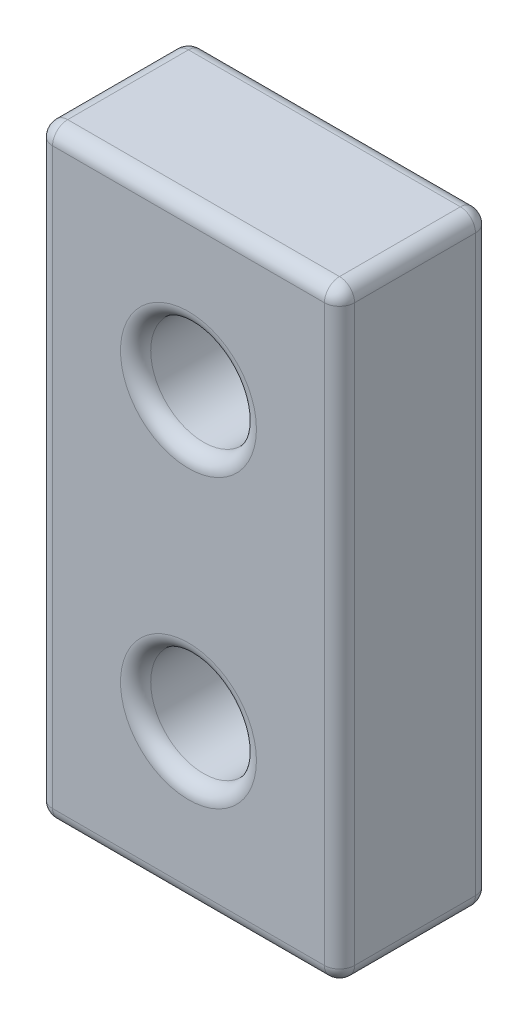
from build123d import *

# Parameters (mm, degrees)
BOSS_EXTRUDE1_DEPTH             = 10
M8X1_0_TAPPED_HOLE1_D           = 7
M8X1_0_TAPPED_HOLE1_CSINK_D     = 8.05
M8X1_0_TAPPED_HOLE1_CSINK_ANGLE = 90
FILLET1_R                       = 1


with BuildPart() as part:
    # Sketch1 → Boss-Extrude1 (new body)
    with BuildSketch(Plane.XY):
        with BuildLine():
            Line((-9, -20), (9, -20))
            ThreePointArc((9, -20), (9.707106781, -19.707106781), (10, -19))
            Line((10, -19), (10, 19))
            ThreePointArc((10, 19), (9.707106781, 19.707106781), (9, 20))
            Line((9, 20), (-9, 20))
            ThreePointArc((-9, 20), (-9.707106781, 19.707106781), (-10, 19))
            Line((-10, 19), (-10, -19))
            ThreePointArc((-10, -19), (-9.707106781, -19.707106781), (-9, -20))
        make_face()
    extrude(amount=BOSS_EXTRUDE1_DEPTH)

    # M8x1.0 Tapped Hole1 (through all)
    with Locations(Plane(origin=(0, 0, 0), x_dir=(-1, 0, 0), z_dir=(0, 0, -1))):
        with Locations((0, 9.5), (0, -9.5)):
            CounterSinkHole(M8X1_0_TAPPED_HOLE1_D / 2, M8X1_0_TAPPED_HOLE1_CSINK_D / 2, counter_sink_angle=M8X1_0_TAPPED_HOLE1_CSINK_ANGLE)

    # Fillet1
    fillet1_edges = [part.edges().sort_by_distance(p)[0] for p in [
        (9.707106781, 19.707106781, 10),
        (10, 0, 0),
        (9.707106781, -19.707106781, 0),
        (0, 20, 10),
        (-9.707106781, 19.707106781, 10),
        (-10, 0, 10),
        (-9.707106781, -19.707106781, 10),
        (0, -20, 10),
        (-4.025, -9.5, 0),
        (-3.5, -9.5, 10),
        (-4.025, 9.5, 0),
        (-3.5, 9.5, 10),
        (9.707106781, -19.707106781, 10),
        (10, 0, 10),
        (0, -20, 0),
        (-9.707106781, -19.707106781, 0),
        (-10, 0, 0),
        (-9.707106781, 19.707106781, 0),
        (0, 20, 0),
        (9.707106781, 19.707106781, 0),
    ]]
    fillet(fillet1_edges, radius=FILLET1_R)


solid = part.part
